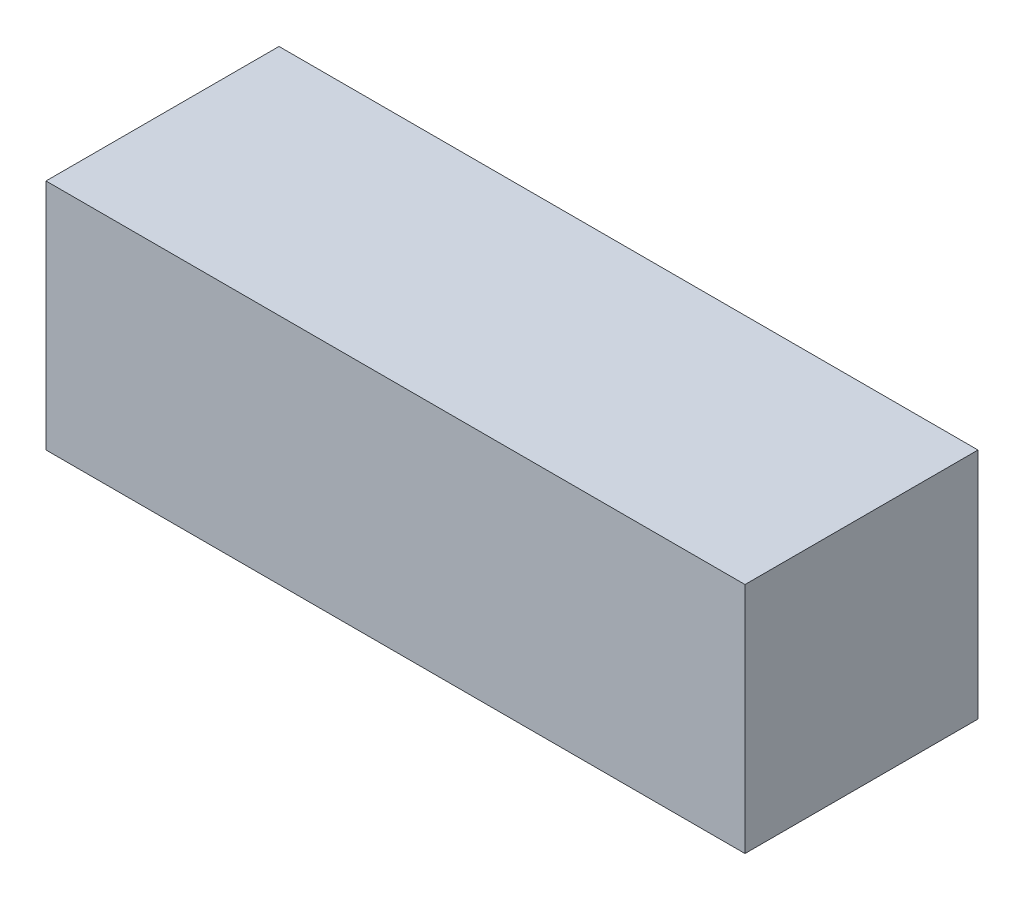
from build123d import *

# Parameters (mm, degrees)
SKETCH2_W           = 300
SKETCH2_H           = 100
BOSS_EXTRUDE1_DEPTH = 100


with BuildPart() as part:
    # Sketch2 → Boss-Extrude1 (new body)
    with BuildSketch(Plane.XY):
        with Locations((150, 50)):
            Rectangle(SKETCH2_W, SKETCH2_H)
    extrude(amount=BOSS_EXTRUDE1_DEPTH)


solid = part.part
